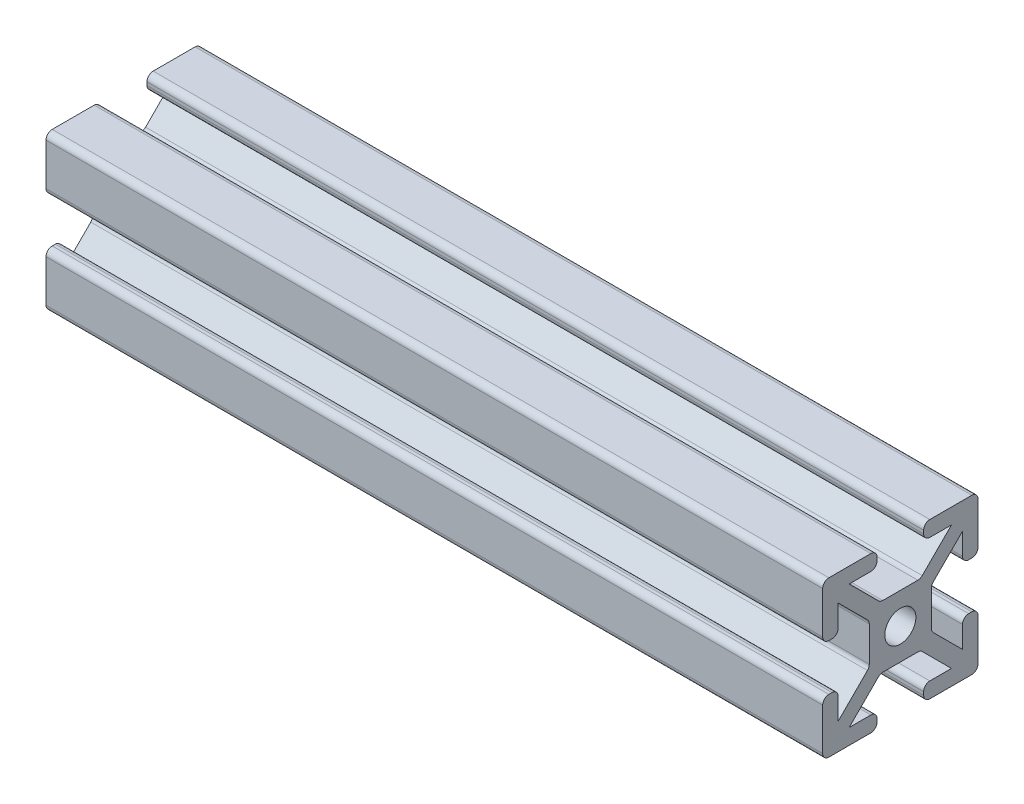
from build123d import *

# Parameters (mm, degrees)
SKETCH11_R         = 2
SIZE_4X4_1_DEPTH   = 100
SKETCH12_R         = 2.5
CUT_EXTRUDE1_DEPTH = 10


with BuildPart() as part:
    # Sketch11 → Size 4X4 (1) (new body)
    with BuildSketch(Plane(origin=(0, 0, 0), x_dir=(0, 0, -1), z_dir=(1, 0, 0))):
        with BuildLine():
            Line((-3, 9.2), (-3, 8.8))
            ThreePointArc((-3, 8.8), (-3.234314575, 8.234314575), (-3.8, 8))
            Line((-3.8, 8), (-6.585786438, 8))
            Line((-6.585786438, 8), (-2.820101013, 4.234314575))
            ThreePointArc((-2.820101013, 4.234314575), (-2.560562334, 4.060896374), (-2.254415588, 4))
            Line((-2.254415588, 4), (2.254415588, 4))
            ThreePointArc((2.254415588, 4), (2.560562334, 4.060896374), (2.820101013, 4.234314575))
            Line((2.820101013, 4.234314575), (6.585786438, 8))
            Line((6.585786438, 8), (3.8, 8))
            ThreePointArc((3.8, 8), (3.234314575, 8.234314575), (3, 8.8))
            Line((3, 8.8), (3, 9.2))
            ThreePointArc((3, 9.2), (3.234314575, 9.765685425), (3.8, 10))
            Line((3.8, 10), (9.2, 10))
            ThreePointArc((9.2, 10), (9.765685425, 9.765685425), (10, 9.2))
            Line((10, 9.2), (10, 3.8))
            ThreePointArc((10, 3.8), (9.765685425, 3.234314575), (9.2, 3))
            Line((9.2, 3), (8.8, 3))
            ThreePointArc((8.8, 3), (8.234314575, 3.234314575), (8, 3.8))
            Line((8, 3.8), (8, 6.585786438))
            Line((8, 6.585786438), (4.234314575, 2.820101013))
            ThreePointArc((4.234314575, 2.820101013), (4.060896374, 2.560562334), (4, 2.254415588))
            Line((4, 2.254415588), (4, -2.254415588))
            ThreePointArc((4, -2.254415588), (4.060896374, -2.560562334), (4.234314575, -2.820101013))
            Line((4.234314575, -2.820101013), (8, -6.585786438))
            Line((8, -6.585786438), (8, -3.8))
            ThreePointArc((8, -3.8), (8.234314575, -3.234314575), (8.8, -3))
            Line((8.8, -3), (9.2, -3))
            ThreePointArc((9.2, -3), (9.765685425, -3.234314575), (10, -3.8))
            Line((10, -3.8), (10, -9.2))
            ThreePointArc((10, -9.2), (9.765685425, -9.765685425), (9.2, -10))
            Line((9.2, -10), (3.8, -10))
            ThreePointArc((3.8, -10), (3.234314575, -9.765685425), (3, -9.2))
            Line((3, -9.2), (3, -8.8))
            ThreePointArc((3, -8.8), (3.234314575, -8.234314575), (3.8, -8))
            Line((3.8, -8), (6.585786438, -8))
            Line((6.585786438, -8), (2.820101013, -4.234314575))
            ThreePointArc((2.820101013, -4.234314575), (2.560562334, -4.060896374), (2.254415588, -4))
            Line((2.254415588, -4), (-2.254415588, -4))
            ThreePointArc((-2.254415588, -4), (-2.560562334, -4.060896374), (-2.820101013, -4.234314575))
            Line((-2.820101013, -4.234314575), (-6.585786438, -8))
            Line((-6.585786438, -8), (-3.8, -8))
            ThreePointArc((-3.8, -8), (-3.234314575, -8.234314575), (-3, -8.8))
            Line((-3, -8.8), (-3, -9.2))
            ThreePointArc((-3, -9.2), (-3.234314575, -9.765685425), (-3.8, -10))
            Line((-3.8, -10), (-9.2, -10))
            ThreePointArc((-9.2, -10), (-9.765685425, -9.765685425), (-10, -9.2))
            Line((-10, -9.2), (-10, -3.8))
            ThreePointArc((-10, -3.8), (-9.765685425, -3.234314575), (-9.2, -3))
            Line((-9.2, -3), (-8.8, -3))
            ThreePointArc((-8.8, -3), (-8.234314575, -3.234314575), (-8, -3.8))
            Line((-8, -3.8), (-8, -6.585786438))
            Line((-8, -6.585786438), (-4.234314575, -2.820101013))
            ThreePointArc((-4.234314575, -2.820101013), (-4.060896374, -2.560562334), (-4, -2.254415588))
            Line((-4, -2.254415588), (-4, 2.254415588))
            ThreePointArc((-4, 2.254415588), (-4.060896374, 2.560562334), (-4.234314575, 2.820101013))
            Line((-4.234314575, 2.820101013), (-8, 6.585786438))
            Line((-8, 6.585786438), (-8, 3.8))
            ThreePointArc((-8, 3.8), (-8.234314575, 3.234314575), (-8.8, 3))
            Line((-8.8, 3), (-9.2, 3))
            ThreePointArc((-9.2, 3), (-9.765685425, 3.234314575), (-10, 3.8))
            Line((-10, 3.8), (-10, 9.2))
            ThreePointArc((-10, 9.2), (-9.765685425, 9.765685425), (-9.2, 10))
            Line((-9.2, 10), (-3.8, 10))
            ThreePointArc((-3.8, 10), (-3.234314575, 9.765685425), (-3, 9.2))
        make_face()
        Circle(SKETCH11_R, mode=Mode.SUBTRACT)
    extrude(amount=SIZE_4X4_1_DEPTH)

    # Sketch12 → Cut-Extrude1 (cut)
    with BuildSketch(Plane(origin=(0, 0, -4), x_dir=(-1, 0, 0), z_dir=(0, 0, -1))):
        with Locations(Location((-90, 0, 0), (0, 0, 295.608789007))):
            Circle(SKETCH12_R)
    extrude(amount=-CUT_EXTRUDE1_DEPTH, mode=Mode.SUBTRACT)


solid = part.part
